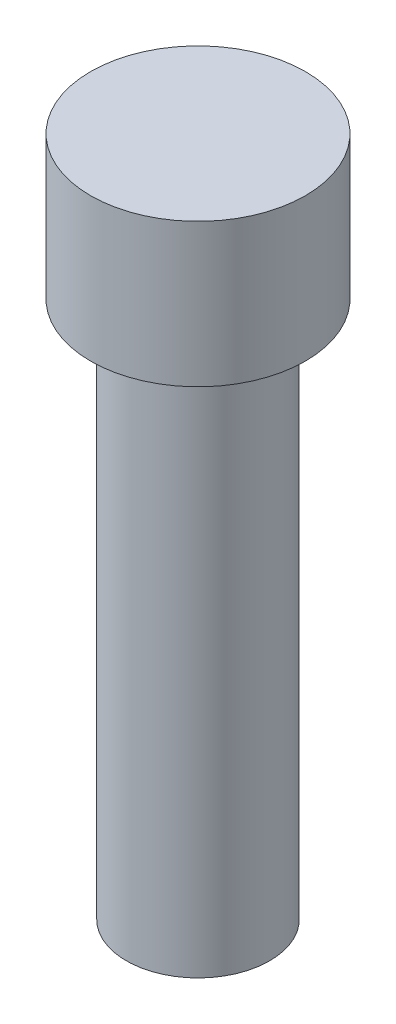
from build123d import *


with BuildPart() as part:
    # Sketch1 → Revolve1 (revolve)
    with BuildSketch(Plane.XY):
        Polygon((0, 0), (-2, 0), (-2, 15), (-3, 15), (-3, 19), (0, 19), align=None)
    revolve(axis=Axis((0, 0, 0), (0, 1, 0)))


solid = part.part
